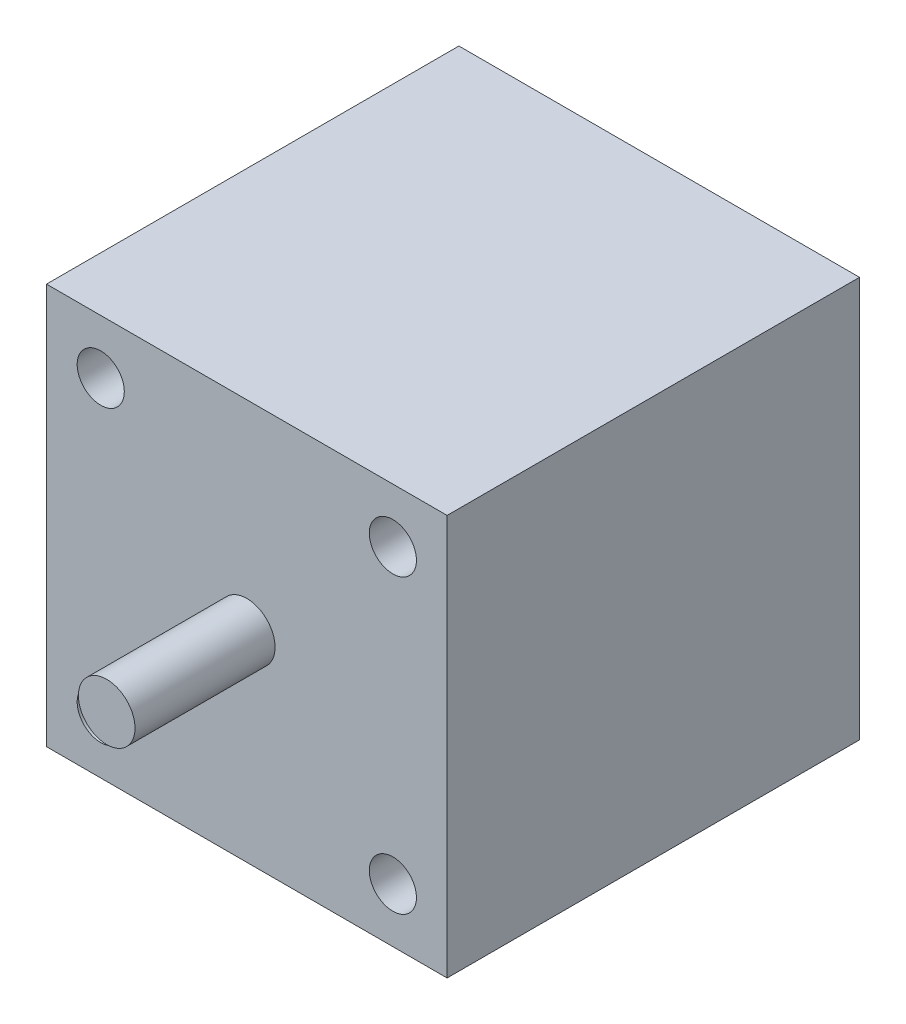
from build123d import *

# Parameters (mm, degrees)
SKETCH1_W           = 42.5
SKETCH1_H           = 42.5
BOSS_EXTRUDE1_DEPTH = 43.75
SKETCH2_R           = 2.5
CUT_EXTRUDE1_DEPTH  = 5
SKETCH3_R           = 3
BOSS_EXTRUDE2_DEPTH = 14.86


with BuildPart() as part:
    # Sketch1 → Boss-Extrude1 (new body)
    with BuildSketch(Plane.XY):
        Rectangle(SKETCH1_W, SKETCH1_H)
    extrude(amount=BOSS_EXTRUDE1_DEPTH)

    # Sketch2 → Cut-Extrude1 (cut)
    with BuildSketch(Plane.XY.offset(43.75)):
        with Locations((-15.495, 15.495)):
            Circle(SKETCH2_R)
        with Locations((15.495, 15.495)):
            Circle(SKETCH2_R)
        with Locations((15.495, -15.495)):
            Circle(SKETCH2_R)
        with Locations((-15.495, -15.495)):
            Circle(SKETCH2_R)
    extrude(amount=-CUT_EXTRUDE1_DEPTH, mode=Mode.SUBTRACT)

    # Sketch3 → Boss-Extrude2 (add)
    with BuildSketch(Plane.XY.offset(43.75)):
        Circle(SKETCH3_R)
    extrude(amount=BOSS_EXTRUDE2_DEPTH)


solid = part.part
